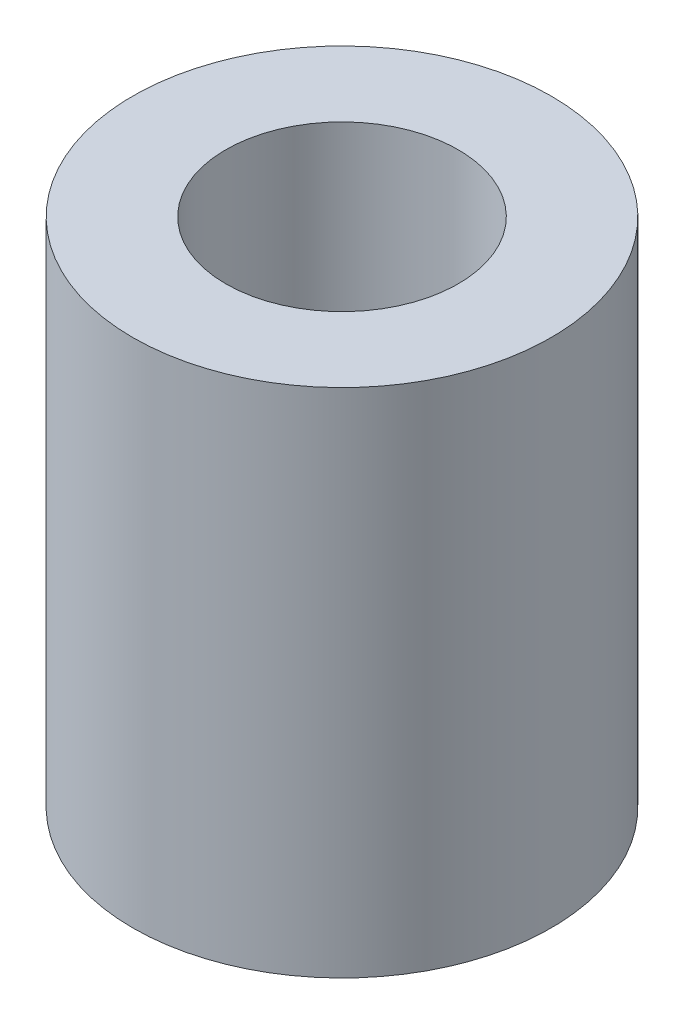
from build123d import *

# Parameters (mm, degrees)
SKETCH2_R           = 2.7
SKETCH2_R_2         = 1.5
BOSS_EXTRUDE1_DEPTH = 6.6


with BuildPart() as part:
    # Sketch2 → Boss-Extrude1 (new body)
    with BuildSketch(Plane(origin=(0, 0, 0), x_dir=(1, 0, 0), z_dir=(0, 1, 0))):
        Circle(SKETCH2_R)
        Circle(SKETCH2_R_2, mode=Mode.SUBTRACT)
    extrude(amount=BOSS_EXTRUDE1_DEPTH)


solid = part.part
